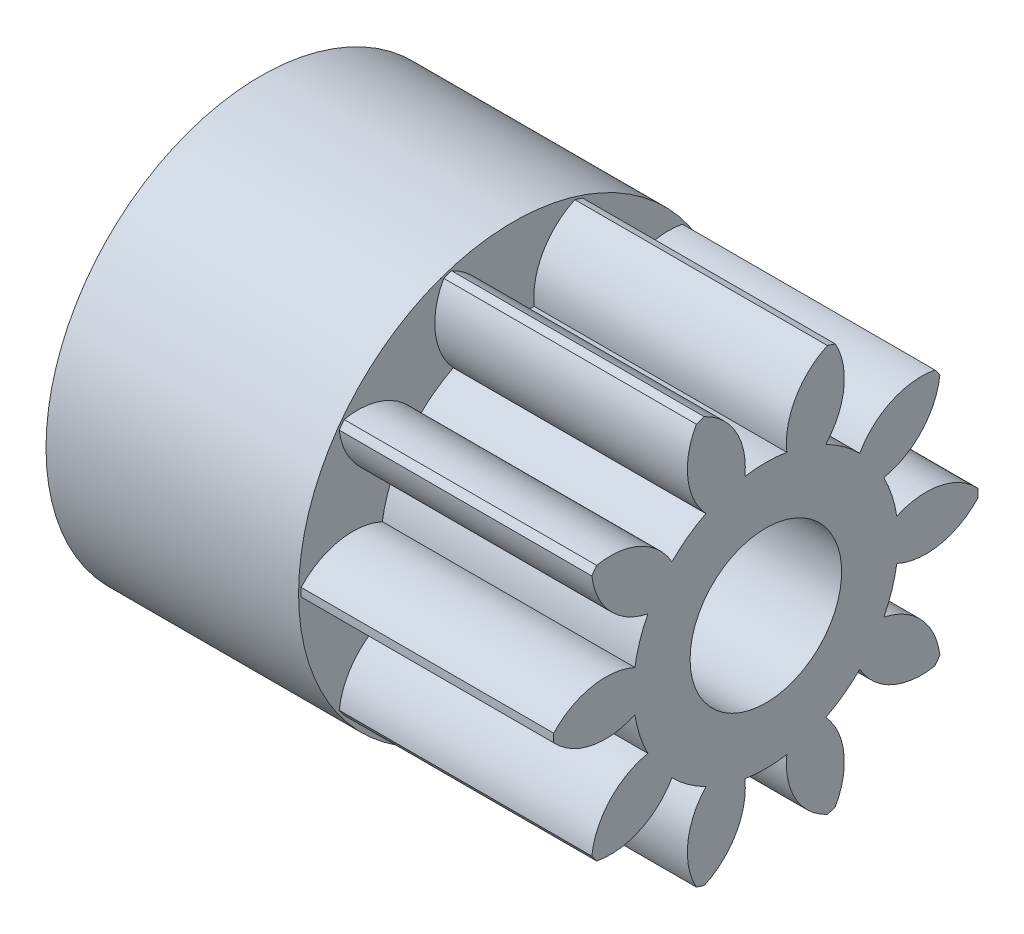
from build123d import *

# Parameters (mm, degrees)
BASPROSKE_W             = 5
BASPROSKE_H             = 4.2
TOOTHCUT_DEPTH          = 8.764019578
TEETHCUTS_COUNT         = 10
TEETHCUTS_ANGLE         = 324
BORSKE_R                = 1.5
BORE_DEPTH              = 50.0000508
CROQUIS1_R              = 4.25
CROQUIS1_R_2            = 3.25
SALIENTE_EXTRUIR1_DEPTH = 5
CROQUIS2_R              = 3.25
SALIENTE_EXTRUIR2_DEPTH = 2
SALIENTE_EXTRUIR3_DEPTH = 2


with BuildPart() as part:
    # BasProSke → Base-Revolve (revolve)
    with BuildSketch(Plane(origin=(0, 0, 0), x_dir=(1, 0, 0), z_dir=(0, 1, 0)), mode=Mode.PRIVATE) as base_revolve_sk:
        with Locations((2.5, 2.1)):
            Rectangle(BASPROSKE_W, BASPROSKE_H)
    revolve(base_revolve_sk.sketch.rotate(Axis((-10, 0, 0), (1, 0, 0)), 180), axis=Axis((-10, 0, 0), (1, 0, 0)))

    # TooCutSke → ToothCut (cut, through all)
    with BuildSketch(Plane(origin=(0, 0, 0), x_dir=(0, 0, -1), z_dir=(1, 0, 0))):
        with BuildLine():
            ThreePointArc((0.415506654, 2.590893711), (0, 2.624), (-0.415506654, 2.590893711))
            ThreePointArc((-0.415506654, 2.590893711), (-0.596160737, 3.451685568), (-1.254578949, 4.034852763))
            ThreePointArc((-1.254578949, 4.034852763), (0, 4.2254), (1.254578949, 4.034852763))
            ThreePointArc((1.254578949, 4.034852763), (0.596160737, 3.451685568), (0.415506654, 2.590893711))
        make_face()
    toothcut = extrude(amount=TOOTHCUT_DEPTH, mode=Mode.SUBTRACT)

    # TeethCuts: ToothCut ×10 about axis
    teethcuts_axis = Axis((-10, 0, 0), (1, 0, 0))
    for i in range(1, TEETHCUTS_COUNT):
        add(toothcut.rotate(teethcuts_axis, i * TEETHCUTS_ANGLE / (TEETHCUTS_COUNT - 1)), mode=Mode.SUBTRACT)

    # BorSke → Bore (cut, symmetric)
    with BuildSketch(Plane(origin=(0, 0, 0), x_dir=(0, 0, -1), z_dir=(1, 0, 0))):
        with Locations(Location((0, 0, 0), (0, 0, 180))):
            Circle(BORSKE_R)
    extrude(amount=BORE_DEPTH, both=True, mode=Mode.SUBTRACT)

    # Croquis1 → Saliente-Extruir1 (add)
    with BuildSketch(Plane.ZY):
        Circle(CROQUIS1_R)
        with Locations(Location((0, 0, 0), (0, 0, 189.396976621))):
            Circle(CROQUIS1_R_2, mode=Mode.SUBTRACT)
    extrude(amount=SALIENTE_EXTRUIR1_DEPTH)

    # Croquis2 → Saliente-Extruir2 (add)
    with BuildSketch(Plane.ZY):
        Circle(CROQUIS2_R)
    extrude(amount=SALIENTE_EXTRUIR2_DEPTH)

    # Croquis3 → Saliente-Extruir3 (add)
    with BuildSketch(Plane.ZY.offset(2)):
        with BuildLine():
            Line((-1.95, 2.6), (-1.95, -2.6))
            ThreePointArc((-1.95, -2.6), (-3.25, 0), (-1.95, 2.6))
        make_face()
    extrude(amount=SALIENTE_EXTRUIR3_DEPTH)


solid = part.part
